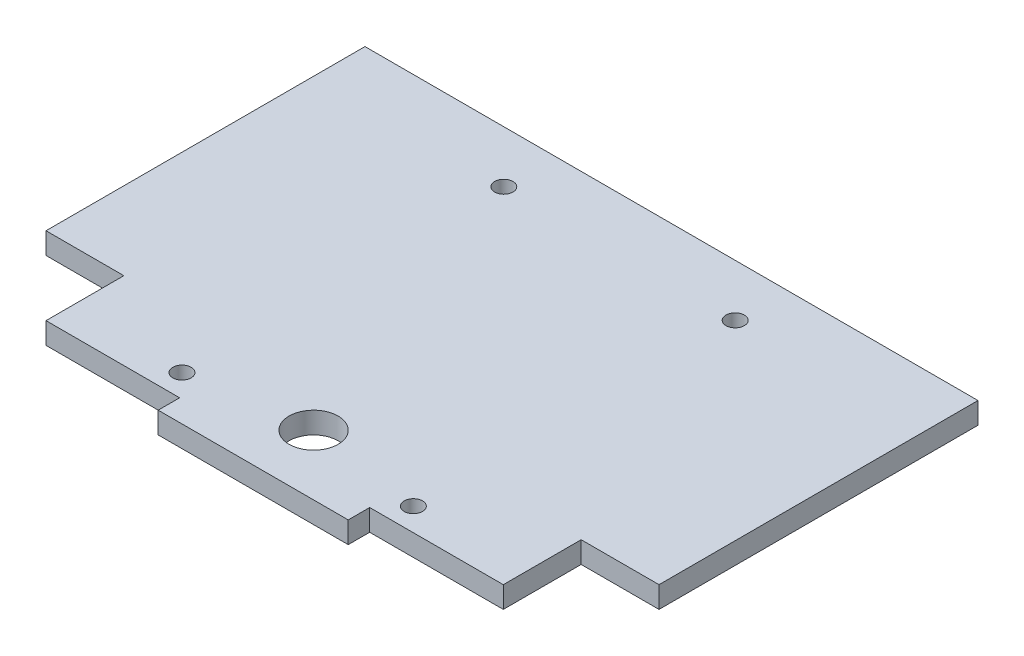
from build123d import *

# Parameters (mm, degrees)
SKETCH1_W                = 31
SKETCH1_H                = 7
SKETCH1_W_2              = 100
SKETCH1_H_2              = 45
BOSS_EXTRUDE1_DEPTH      = 7
F_6_0_6_DIAMETER_HOLE1_D = 6


with BuildPart() as part:
    # Sketch1 → Boss-Extrude1 (new body)
    with BuildSketch(Plane(origin=(0, 0, 0), x_dir=(1, 0, 0), z_dir=(0, 1, 0))):
        with BuildLine():
            Line((-31, 0), (0, 0))
            Line((0, 0), (0, 4.7))
            ThreePointArc((0, 4.7), (-8, 12.7), (0, 20.7))
            Line((0, 20.7), (0, 84.468576745))
            Line((0, 84.468576745), (-100, 84.468576745))
            Line((-100, 84.468576745), (-100, 25.4))
            Line((-100, 25.4), (-74.6, 25.4))
            Line((-74.6, 25.4), (-74.6, 0))
            Line((-74.6, 0), (-31, 0))
        make_face()
        with Locations((-15.5, -3.5)):
            Rectangle(SKETCH1_W, SKETCH1_H)
        with Locations((-50, 106.968576745)):
            Rectangle(SKETCH1_W_2, SKETCH1_H_2)
    boss_extrude1 = extrude(amount=BOSS_EXTRUDE1_DEPTH)

    # Mirror1: Boss-Extrude1 across Right Plane
    add(boss_extrude1.mirror(Plane(origin=(0, 0, 0), x_dir=(0, 0, -1), z_dir=(1, 0, 0))))

    # Ø6.0 (6) Diameter Hole1 (through all)
    with Locations(Plane(origin=(-37.75, 7, -7.5), x_dir=(0, 0, 1), z_dir=(0, 1, 0))):
        with Locations((0, 0), (0, 75.5), (-105, 75.5), (-105, 0)):
            Hole(F_6_0_6_DIAMETER_HOLE1_D / 2)


solid = part.part
